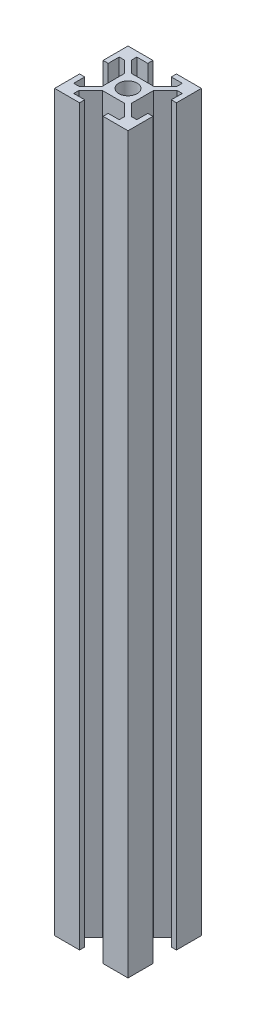
from build123d import *

# Parameters (mm, degrees)
SKETCH1_R           = 2.5
BOSS_EXTRUDE1_DEPTH = 200


with BuildPart() as part:
    # Sketch1 → Boss-Extrude1 (new body)
    with BuildSketch(Plane(origin=(0, 0, 0), x_dir=(1, 0, 0), z_dir=(0, 1, 0))):
        Polygon((-3.2, 10), (-3.2, 8.6), (-6.2, 8.6), (-6.2, 7.189949494), (-3, 3.989949494), (3, 3.989949494), (6.2, 7.189949494), (6.2, 8.6), (3.2, 8.6), (3.2, 10), (10, 10), (10, 3.2), (8.6, 3.2), (8.6, 6.2), (7.189949494, 6.2), (3.989949494, 3), (3.989949494, -3), (7.189949494, -6.2), (8.6, -6.2), (8.6, -3.2), (10, -3.2), (10, -10), (3.2, -10), (3.2, -8.6), (6.2, -8.6), (6.2, -7.189949494), (3, -3.989949494), (-3, -3.989949494), (-6.2, -7.189949494), (-6.2, -8.6), (-3.2, -8.6), (-3.2, -10), (-10, -10), (-10, -3.2), (-8.6, -3.2), (-8.6, -6.2), (-7.189949494, -6.2), (-3.989949494, -3), (-3.989949494, 3), (-7.189949494, 6.2), (-8.6, 6.2), (-8.6, 3.2), (-10, 3.2), (-10, 10), align=None)
        Circle(SKETCH1_R, mode=Mode.SUBTRACT)
    extrude(amount=BOSS_EXTRUDE1_DEPTH)


solid = part.part
